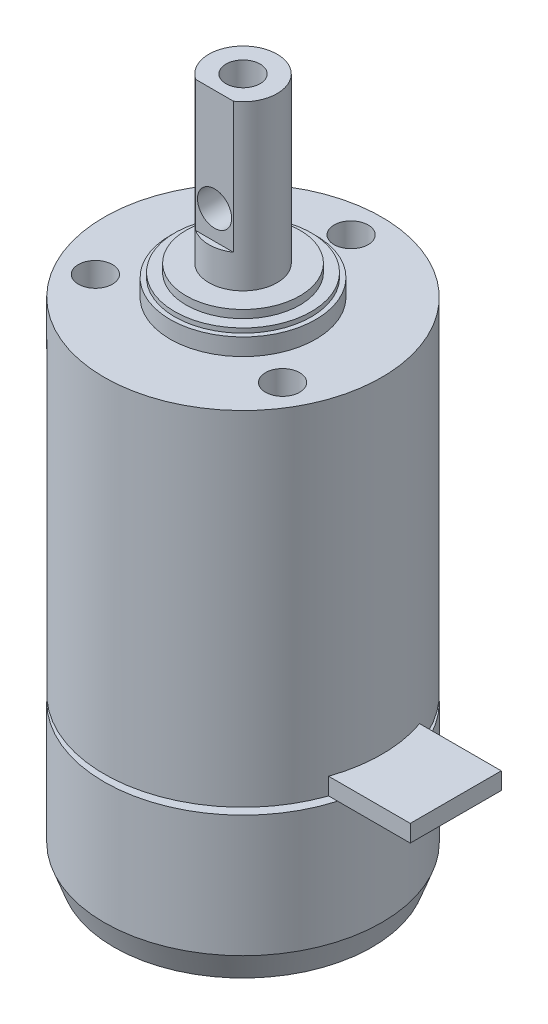
from build123d import *

# Parameters (mm, degrees)
SKETCH_1_R          = 12.2
EXTRUDE_1_DEPTH     = 43.8
SKETCH_3_R          = 1.5
CUT_EXTRUDE_1_DEPTH = 4
CHAMFER_1_SIZE      = 0.85
CHAMFER_1_SIZE2     = 2.3
SKETCH_4_R          = 6.4
EXTRUDE_2_DEPTH     = 1.5
SKETCH_5_R          = 6
EXTRUDE_3_DEPTH     = 0.4
SKETCH_6_R          = 5
EXTRUDE_4_DEPTH     = 0.7
SKETCH_7_R          = 3
EXTRUDE_5_DEPTH     = 14.4
SKETCH_8_R          = 1.5
CUT_EXTRUDE_2_DEPTH = 5.5
CUT_EXTRUDE_3_DEPTH = 11.5
SKETCH_10_R         = 1.5
CUT_EXTRUDE_4_DEPTH = 15.7
CUT_EXTRUDE_START   = -13
SKETCH_11_R         = 12.2
SKETCH_11_R_2       = 7
CUT_EXTRUDE_5_DEPTH = 0.6
EXTRUDE_6_REACH     = 32.9
SKETCH_12_W         = 8
SKETCH_12_H         = 1.5
SKETCH_13_R         = 1
CUT_EXTRUDE_6_DEPTH = 3
SKETCH_14_R         = 3
EXTRUDE_7_DEPTH     = 4
CHAMFER_2_SIZE      = 0.2
CHAMFER_2_SIZE2     = 0.1


with BuildPart() as part:
    # 草图1 → 凸台-拉伸1 (new body)
    with BuildSketch(Plane(origin=(0, 0, 0), x_dir=(1, 0, 0), z_dir=(0, 1, 0))):
        Circle(SKETCH_1_R)
    extrude(amount=EXTRUDE_1_DEPTH)

    # 草图3 → 切除-拉伸1 (cut)
    with BuildSketch(Plane(origin=(0, 43.8, 0), x_dir=(1, 0, 0), z_dir=(0, 1, 0))):
        with Locations((0, 9.5)):
            Circle(SKETCH_3_R)
        with Locations((-8.227241336, -4.75)):
            Circle(SKETCH_3_R)
        with Locations((8.227241336, -4.75)):
            Circle(SKETCH_3_R)
    extrude(amount=-CUT_EXTRUDE_1_DEPTH, mode=Mode.SUBTRACT)

    # 倒角1
    chamfer_1_edges = [part.edges().sort_by_distance(p)[0] for p in [
        (-12.2, 0, 0),
    ]]
    chamfer_1_side = [part.faces().sort_by_distance(p)[0] for p in [
        (0, 0, 0),
    ]]
    chamfer(chamfer_1_edges, length=CHAMFER_1_SIZE, length2=CHAMFER_1_SIZE2, reference=chamfer_1_side[0])

    # 草图4 → 凸台-拉伸2 (add)
    with BuildSketch(Plane(origin=(0, 43.8, 0), x_dir=(1, 0, 0), z_dir=(0, 1, 0))):
        Circle(SKETCH_4_R)
    extrude(amount=EXTRUDE_2_DEPTH)

    # 草图5 → 凸台-拉伸3 (add)
    with BuildSketch(Plane(origin=(0, 45.3, 0), x_dir=(1, 0, 0), z_dir=(0, 1, 0))):
        Circle(SKETCH_5_R)
    extrude(amount=EXTRUDE_3_DEPTH)

    # 草图6 → 凸台-拉伸4 (add)
    with BuildSketch(Plane(origin=(0, 45.7, 0), x_dir=(1, 0, 0), z_dir=(0, 1, 0))):
        Circle(SKETCH_6_R)
    extrude(amount=EXTRUDE_4_DEPTH)

    # 草图7 → 凸台-拉伸5 (add)
    with BuildSketch(Plane(origin=(0, 46.4, 0), x_dir=(1, 0, 0), z_dir=(0, 1, 0))):
        Circle(SKETCH_7_R)
    extrude(amount=EXTRUDE_5_DEPTH)

    # 草图8 → 切除-拉伸2 (cut)
    with BuildSketch(Plane(origin=(0, 60.8, 0), x_dir=(1, 0, 0), z_dir=(0, 1, 0))):
        Circle(SKETCH_8_R)
    extrude(amount=-CUT_EXTRUDE_2_DEPTH, mode=Mode.SUBTRACT)

    # 草图9 → 切除-拉伸3 (cut)
    with BuildSketch(Plane(origin=(0, 60.8, 0), x_dir=(1, 0, 0), z_dir=(0, 1, 0))):
        with BuildLine():
            Line((-1.658312395, -2.5), (1.658312395, -2.5))
            ThreePointArc((1.658312395, -2.5), (0, -3), (-1.658312395, -2.5))
        make_face()
    extrude(amount=-CUT_EXTRUDE_3_DEPTH, mode=Mode.SUBTRACT)

    # 草图10 → 切除-拉伸4 (cut, through all)
    with BuildSketch(Plane.XY.offset(2.5)):
        with Locations((0, 51.8)):
            Circle(SKETCH_10_R)
    extrude(amount=-CUT_EXTRUDE_4_DEPTH, mode=Mode.SUBTRACT)

    # 草图11 → 切除-拉伸5 (cut)
    with BuildSketch(Plane.XZ.offset(CUT_EXTRUDE_START)):
        Circle(SKETCH_11_R)
        Circle(SKETCH_11_R_2, mode=Mode.SUBTRACT)
    extrude(amount=-CUT_EXTRUDE_5_DEPTH, mode=Mode.SUBTRACT)

    # 草图12 → 凸台-拉伸6 (add, up to next)
    with BuildSketch(Plane(origin=(18.7, 0, 0), x_dir=(0, 0, -1), z_dir=(1, 0, 0)), mode=Mode.PRIVATE) as extrude_6_sk1:
        with Locations((0, 14.35)):
            Rectangle(SKETCH_12_W, SKETCH_12_H)
    extrude_6_tool1 = extrude(extrude_6_sk1.sketch, amount=-EXTRUDE_6_REACH, mode=Mode.PRIVATE) - part.part
    add(extrude_6_tool1.solids().sort_by_distance((18.7, 14.35, 0))[0])

    # 草图13 → 切除-拉伸6 (cut)
    with BuildSketch(Plane.XZ):
        with Locations((0, 5.5)):
            Circle(SKETCH_13_R)
        with Locations((-4.763139721, -2.75)):
            Circle(SKETCH_13_R)
        with Locations((4.763139721, -2.75)):
            Circle(SKETCH_13_R)
    extrude(amount=-CUT_EXTRUDE_6_DEPTH, mode=Mode.SUBTRACT)

    # 草图14 → 凸台-拉伸7 (add)
    with BuildSketch(Plane.XZ):
        Circle(SKETCH_14_R)
    extrude(amount=EXTRUDE_7_DEPTH)

    # 倒角2
    chamfer_2_edges = [part.edges().sort_by_distance(p)[0] for p in [
        (-3, -4, 0),
    ]]
    chamfer_2_side = [part.faces().sort_by_distance(p)[0] for p in [
        (-3, -2, 0),
    ]]
    chamfer(chamfer_2_edges, length=CHAMFER_2_SIZE, length2=CHAMFER_2_SIZE2, reference=chamfer_2_side[0])


solid = part.part
